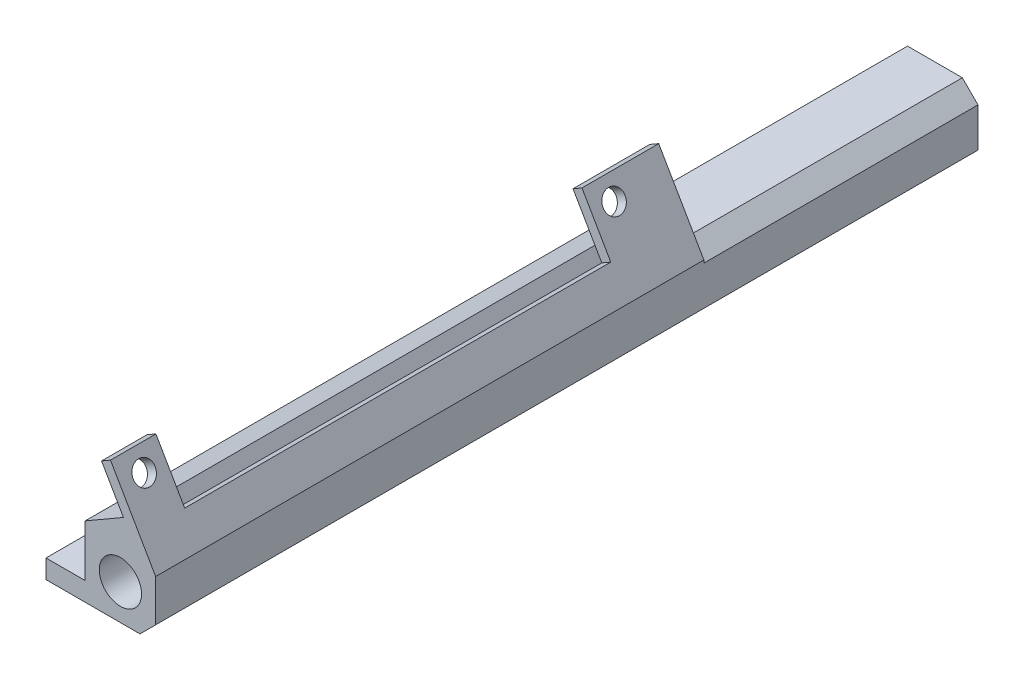
from build123d import *

# Parameters (mm, degrees)
SKETCH1_W           = 77.47
SKETCH1_H           = 133.35
BOSS_EXTRUDE1_DEPTH = 11.43
SKETCH2_R           = 3.429
CUT_EXTRUDE1_DEPTH  = 134.35
CUT_EXTRUDE2_DEPTH  = 12.43
SKETCH4_W           = 54.61
SKETCH4_H           = 6.35
CUT_EXTRUDE3_DEPTH  = 134.35
CHAMFER1_SIZE       = 2.54
SKETCH5_W           = 66.04
SKETCH5_H           = 50.8
CUT_EXTRUDE4_DEPTH  = 12.43
SKETCH6_W           = 53.34
SKETCH6_H           = 82.55
CUT_EXTRUDE5_DEPTH  = 12.43
SKETCH7_R           = 1.778
HOLE_CUTS_1_DEPTH   = 6.08
BOSS_EXTRUDE2_DEPTH = 88.9
CUT_EXTRUDE7_REACH  = 135.35
SKETCH9_W           = 6.35
SKETCH9_H           = 5.08
CUT_EXTRUDE8_REACH  = 135.35
SKETCH10_W          = 6.35
SKETCH10_H          = 1.27
HOLE_CUTS_2_REACH   = 10.608
SKETCH11_R          = 1.778
SKETCH12_W          = 88.9
SKETCH12_H          = 11.176
CUT_EXTRUDE10_DEPTH = 1.27
CUT_EXTRUDE15_DEPTH = 134.35
SKETCH14_W          = 6.35
SKETCH14_H          = 82.55
CUT_EXTRUDE12_DEPTH = 0.762
SKETCH15_W          = 1.676805635
SKETCH15_H          = 88.9
BOSS_EXTRUDE3_DEPTH = 1.27
CUT_EXTRUDE13_REACH = 10.019
SKETCH16_W          = 69.088
SKETCH16_H          = 9.3345
CUT_EXTRUDE14_REACH = 12.28
SKETCH17_W          = 1.27
SKETCH17_H          = 88.9


with BuildPart() as part:
    # Sketch1 → Boss-Extrude1 (new body)
    with BuildSketch(Plane(origin=(0, 0, 0), x_dir=(1, 0, 0), z_dir=(0, 1, 0))):
        with Locations((38.735, 66.675)):
            Rectangle(SKETCH1_W, SKETCH1_H)
    extrude(amount=BOSS_EXTRUDE1_DEPTH)

    # Sketch2 → Cut-Extrude1 (cut, through all)
    with BuildSketch(Plane.XY):
        with Locations((5.715, 5.715)):
            Circle(SKETCH2_R)
        with Locations((71.755, 5.715)):
            Circle(SKETCH2_R)
    extrude(amount=-CUT_EXTRUDE1_DEPTH, mode=Mode.SUBTRACT)

    # Sketch3 → Cut-Extrude2 (cut, through all)
    with BuildSketch(Plane(origin=(0, 11.43, 0), x_dir=(1, 0, 0), z_dir=(0, 1, 0))):
        with BuildLine():
            Line((11.43, 133.35), (11.43, 95.25))
            ThreePointArc((11.43, 95.25), (15.149743879, 86.269743879), (24.13, 82.55))
            Line((24.13, 82.55), (53.34, 82.55))
            ThreePointArc((53.34, 82.55), (62.320256121, 86.269743879), (66.04, 95.25))
            Line((66.04, 95.25), (66.04, 133.35))
            Line((66.04, 133.35), (11.43, 133.35))
        make_face()
    extrude(amount=-CUT_EXTRUDE2_DEPTH, mode=Mode.SUBTRACT)

    # Sketch4 → Cut-Extrude3 (cut, through all)
    with BuildSketch(Plane(origin=(0, 0, -133.35), x_dir=(-1, 0, 0), z_dir=(0, 0, -1))):
        with Locations((-38.735, 8.255)):
            Rectangle(SKETCH4_W, SKETCH4_H)
    extrude(amount=-CUT_EXTRUDE3_DEPTH, mode=Mode.SUBTRACT)

    # Chamfer1
    chamfer1_edges = [part.edges().sort_by_distance(p)[0] for p in [
        (77.47, 11.43, -66.675),
        (0, 11.43, -66.675),
        (77.47, 0, -66.675),
        (0, 0, -66.675),
    ]]
    chamfer(chamfer1_edges, length=CHAMFER1_SIZE)

    # Sketch5 → Cut-Extrude4 (cut, through all)
    with BuildSketch(Plane(origin=(0, 11.43, 0), x_dir=(1, 0, 0), z_dir=(0, 1, 0))):
        with Locations((33.02, 107.95)):
            Rectangle(SKETCH5_W, SKETCH5_H)
    extrude(amount=-CUT_EXTRUDE4_DEPTH, mode=Mode.SUBTRACT)

    # Sketch6 → Cut-Extrude5 (cut, through all)
    with BuildSketch(Plane(origin=(0, 11.43, 0), x_dir=(1, 0, 0), z_dir=(0, 1, 0))):
        with Locations((26.67, 41.275)):
            Rectangle(SKETCH6_W, SKETCH6_H)
    extrude(amount=-CUT_EXTRUDE5_DEPTH, mode=Mode.SUBTRACT)

    # Sketch7 → Hole Cuts 1 (cut, through all)
    with BuildSketch(Plane(origin=(0, 5.08, 0), x_dir=(1, 0, 0), z_dir=(0, 1, 0))):
        with Locations((62.23, 74.93)):
            Circle(SKETCH7_R)
        with Locations((62.23, 13.97)):
            Circle(SKETCH7_R)
    extrude(amount=-HOLE_CUTS_1_DEPTH, mode=Mode.SUBTRACT)

    # Sketch8 → Boss-Extrude2 (add)
    with BuildSketch(Plane.XY):
        Polygon((77.47, 11.869940905), (77.47, 8.89), (74.93, 11.43), (66.04, 11.43), (71.539261314, 14.605), (68.618261314, 19.664320409), (71.882, 21.548640818), align=None)
    extrude(amount=-BOSS_EXTRUDE2_DEPTH)

    # Sketch9 → Cut-Extrude7 (cut, up to next)
    with BuildSketch(Plane.XY, mode=Mode.PRIVATE) as cut_extrude7_sk1:
        with Locations((56.515, 2.54)):
            Rectangle(SKETCH9_W, SKETCH9_H)
    cut_extrude7_tool1 = extrude(cut_extrude7_sk1.sketch, amount=-CUT_EXTRUDE7_REACH, mode=Mode.PRIVATE) & part.part
    add(cut_extrude7_tool1.solids().sort_by_distance((56.515, 2.54, 0))[0], mode=Mode.SUBTRACT)

    # Sketch10 → Cut-Extrude8 (cut, up to next)
    with BuildSketch(Plane.XY, mode=Mode.PRIVATE) as cut_extrude8_sk1:
        with Locations((62.865, 4.445)):
            Rectangle(SKETCH10_W, SKETCH10_H)
    cut_extrude8_tool1 = extrude(cut_extrude8_sk1.sketch, amount=-CUT_EXTRUDE8_REACH, mode=Mode.PRIVATE) & part.part
    add(cut_extrude8_tool1.solids().sort_by_distance((62.865, 4.445, 0))[0], mode=Mode.SUBTRACT)

    # Sketch11 → Hole Cuts 2 (cut, up to next)
    with BuildSketch(Plane(origin=(59.978596497, 34.628658833, 0), x_dir=(0, 0, 1), z_dir=(-0.866025404, -0.5, 0)), mode=Mode.PRIVATE) as hole_cuts_2_sk1:
        with Locations((-3.81, -19.311329635)):
            Circle(SKETCH11_R)
    hole_cuts_2_tool1 = extrude(hole_cuts_2_sk1.sketch, amount=-HOLE_CUTS_2_REACH, mode=Mode.PRIVATE) & part.part
    add(hole_cuts_2_tool1.solids().sort_by_distance((69.634261, 17.904557, -3.81))[0], mode=Mode.SUBTRACT)
    # Sketch11 → Hole Cuts 2 (cut, up to next)
    with BuildSketch(Plane(origin=(59.978596497, 34.628658833, 0), x_dir=(0, 0, 1), z_dir=(-0.866025404, -0.5, 0)), mode=Mode.PRIVATE) as hole_cuts_2_sk2:
        with Locations((-80.01, -19.311329635)):
            Circle(SKETCH11_R)
    hole_cuts_2_tool2 = extrude(hole_cuts_2_sk2.sketch, amount=-HOLE_CUTS_2_REACH, mode=Mode.PRIVATE) & part.part
    add(hole_cuts_2_tool2.solids().sort_by_distance((69.634261, 17.904557, -80.01))[0], mode=Mode.SUBTRACT)

    # Sketch12 → Cut-Extrude10 (cut)
    with BuildSketch(Plane(origin=(63.242335183, 36.512979242, 0), x_dir=(0, 0, -1), z_dir=(0.866025404, 0.5, 0))):
        with Locations((44.45, -22.867329635)):
            Rectangle(SKETCH12_W, SKETCH12_H)
    extrude(amount=-CUT_EXTRUDE10_DEPTH, mode=Mode.SUBTRACT)

    # Sketch22 → Cut-Extrude15 (cut, through all)
    with BuildSketch(Plane.XY):
        Polygon((64.930582409, 17.535238), (69.32999146, 20.075238), (72.25099146, 15.015917591), (67.851582409, 12.475917591), align=None)
    extrude(amount=-CUT_EXTRUDE15_DEPTH, mode=Mode.SUBTRACT)

    # Sketch14 → Cut-Extrude12 (cut)
    with BuildSketch(Plane(origin=(0, 3.81, 0), x_dir=(1, 0, 0), z_dir=(0, 1, 0))):
        with Locations((62.865, 41.275)):
            Rectangle(SKETCH14_W, SKETCH14_H)
    extrude(amount=-CUT_EXTRUDE12_DEPTH, mode=Mode.SUBTRACT)

    # Sketch15 → Boss-Extrude3 (add)
    with BuildSketch(Plane(origin=(8.639664817, -14.964338424, 0), x_dir=(0.866025404, 0.5, 0), z_dir=(-0.5, 0.866025404, 0))):
        with Locations((70.917555667, 44.45)):
            Rectangle(SKETCH15_W, SKETCH15_H)
    extrude(amount=BOSS_EXTRUDE3_DEPTH)

    # Sketch16 → Cut-Extrude13 (cut, up to next)
    with BuildSketch(Plane(origin=(60.690326643, 35.039576424, 0), x_dir=(0, 0, 1), z_dir=(-0.866025404, -0.5, 0)), mode=Mode.PRIVATE) as cut_extrude13_sk1:
        with Locations((-41.91, -20.676579635)):
            Rectangle(SKETCH16_W, SKETCH16_H)
    cut_extrude13_tool1 = extrude(cut_extrude13_sk1.sketch, amount=-CUT_EXTRUDE13_REACH, mode=Mode.PRIVATE) & part.part
    add(cut_extrude13_tool1.solids().sort_by_distance((71.028616, 17.133133, -41.91))[0], mode=Mode.SUBTRACT)

    # Sketch17 → Cut-Extrude14 (cut, up to next)
    with BuildSketch(Plane(origin=(14.227664817, -24.643038337, 0), x_dir=(0.866025404, 0.5, 0), z_dir=(-0.5, 0.866025404, 0)), mode=Mode.PRIVATE) as cut_extrude14_sk1:
        with Locations((72.390958484, 44.45)):
            Rectangle(SKETCH17_W, SKETCH17_H)
    cut_extrude14_tool1 = extrude(cut_extrude14_sk1.sketch, amount=-CUT_EXTRUDE14_REACH, mode=Mode.PRIVATE) & part.part
    add(cut_extrude14_tool1.solids().sort_by_distance((76.920074, 11.552441, -44.45))[0], mode=Mode.SUBTRACT)


solid = part.part
